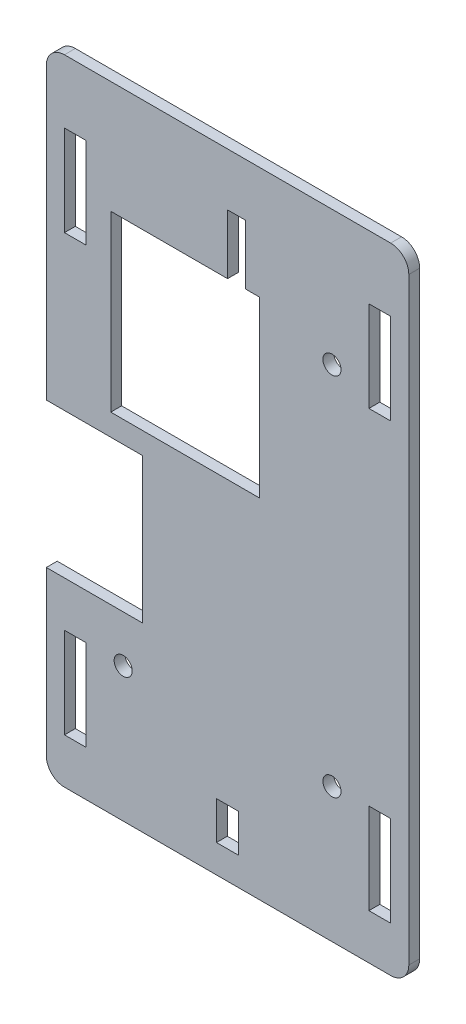
from build123d import *

# Parameters (mm, degrees)
SKETCH1_W           = 200
SKETCH1_H           = 350
SKETCH1_R           = 5
BOSS_EXTRUDE1_DEPTH = 6
FILLET1_R           = 10
SKETCH2_W           = 12
SKETCH2_H           = 50
SKETCH2_W_2         = 54
SKETCH2_H_2         = 80
SKETCH2_W_3         = 12.25
SKETCH2_H_3         = 21
CUT_EXTRUDE1_DEPTH  = 7


with BuildPart() as part:
    # Sketch1 → Boss-Extrude1 (new body)
    with BuildSketch(Plane.XY):
        Rectangle(SKETCH1_W, SKETCH1_H)
        with Locations((-57.588571429, 100.78)):
            Circle(SKETCH1_R, mode=Mode.SUBTRACT)
        with Locations((57.588571429, 100.78)):
            Circle(SKETCH1_R, mode=Mode.SUBTRACT)
        with Locations((57.588571429, -100.78)):
            Circle(SKETCH1_R, mode=Mode.SUBTRACT)
        with Locations((-57.588571429, -100.78)):
            Circle(SKETCH1_R, mode=Mode.SUBTRACT)
    extrude(amount=BOSS_EXTRUDE1_DEPTH)

    # Fillet1
    fillet1_edges = [part.edges().sort_by_distance(p)[0] for p in [
        (100, -175, 3),
        (-100, -175, 3),
        (-100, 175, 3),
        (100, 175, 3),
    ]]
    fillet(fillet1_edges, radius=FILLET1_R)

    # Sketch2 → Cut-Extrude1 (cut, through all)
    with BuildSketch(Plane.XY.offset(6)):
        Polygon((10.001494726, 113), (17.551494726, 113), (17.551494726, 17), (-64.448505274, 17), (-64.448505274, 113), (0.001494726, 113), (0.001494726, 145.880160171), (10.001494726, 145.880160171), align=None)
        with Locations((-84, 115)):
            Rectangle(SKETCH2_W, SKETCH2_H)
        with Locations((-84, -125)):
            Rectangle(SKETCH2_W, SKETCH2_H)
        with Locations((84, -125)):
            Rectangle(SKETCH2_W, SKETCH2_H)
        with Locations((84, 115)):
            Rectangle(SKETCH2_W, SKETCH2_H)
        with Locations((-74, -35)):
            Rectangle(SKETCH2_W_2, SKETCH2_H_2)
        with Locations((0, -149)):
            Rectangle(SKETCH2_W_3, SKETCH2_H_3)
    extrude(amount=-CUT_EXTRUDE1_DEPTH, mode=Mode.SUBTRACT)


solid = part.part
